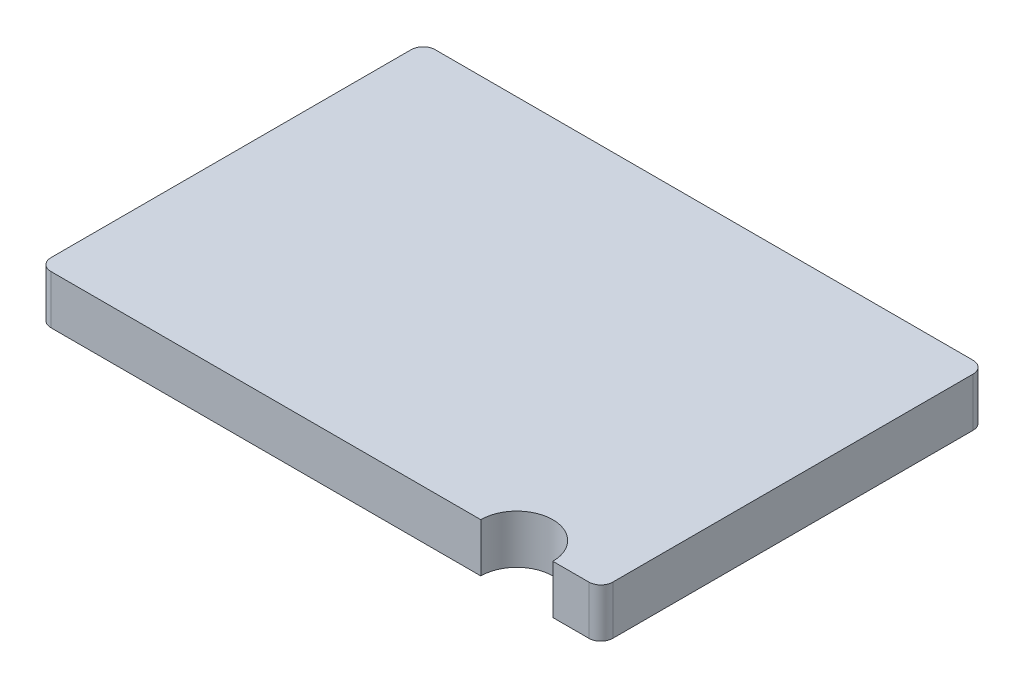
from build123d import *

# Parameters (mm, degrees)
SKETCH1_W           = 2.34
SKETCH1_H           = 1.6
BOSS_EXTRUDE1_DEPTH = 0.203
FILLET1_R           = 0.05
SKETCH2_R           = 0.15
CUT_EXTRUDE1_DEPTH  = 1.203


with BuildPart() as part:
    # Sketch1 → Boss-Extrude1 (new body)
    with BuildSketch(Plane(origin=(0, 0, 0), x_dir=(1, 0, 0), z_dir=(0, 1, 0))):
        Rectangle(SKETCH1_W, SKETCH1_H)
    extrude(amount=BOSS_EXTRUDE1_DEPTH)

    # Fillet1
    fillet1_edges = [part.edges().sort_by_distance(p)[0] for p in [
        (1.17, 0.1015, 0.8),
        (-1.17, 0.1015, 0.8),
        (-1.17, 0.1015, -0.8),
        (1.17, 0.1015, -0.8),
    ]]
    fillet(fillet1_edges, radius=FILLET1_R)

    # Sketch2 → Cut-Extrude1 (cut, through all)
    with BuildSketch(Plane(origin=(0, 0.203, 0), x_dir=(1, 0, 0), z_dir=(0, 1, 0))):
        with Locations((0.82, -0.8)):
            Circle(SKETCH2_R)
    extrude(amount=-CUT_EXTRUDE1_DEPTH, mode=Mode.SUBTRACT)


solid = part.part
